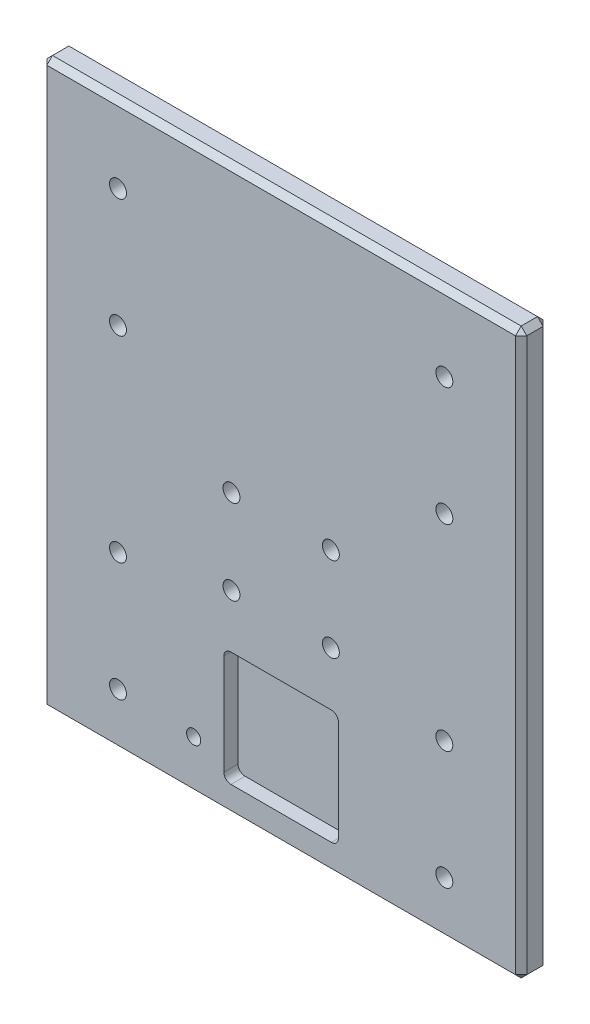
from build123d import *

# Parameters (mm, degrees)
SKETCH1_W           = 107.95
SKETCH1_H           = 127
BOSS_EXTRUDE1_DEPTH = 6.223
CHAMFER1_SIZE       = 1.27
SKETCH2_R           = 1.905
CUT_EXTRUDE1_DEPTH  = 7.223
SKETCH3_R           = 1.905
CUT_EXTRUDE2_DEPTH  = 7.223
SKETCH4_W           = 25.781
SKETCH4_H           = 25.781
CUT_EXTRUDE3_DEPTH  = 3.175
FILLET1_R           = 1.5875
SKETCH5_R           = 1.5875
CUT_EXTRUDE4_DEPTH  = 7.223


with BuildPart() as part:
    # Sketch1 → Boss-Extrude1 (new body)
    with BuildSketch(Plane.XY):
        Rectangle(SKETCH1_W, SKETCH1_H)
    extrude(amount=BOSS_EXTRUDE1_DEPTH)

    # Chamfer1
    chamfer1_edges = [part.edges().sort_by_distance(p)[0] for p in [
        (-53.975, 0, 6.223),
        (0, -63.5, 6.223),
        (53.975, 0, 6.223),
        (0, -63.5, 0),
        (-53.975, 0, 0),
        (0, 63.5, 0),
        (53.975, 0, 0),
        (0, 63.5, 6.223),
        (53.975, -63.5, 3.1115),
        (-53.975, -63.5, 3.1115),
        (-53.975, 63.5, 3.1115),
        (53.975, 63.5, 3.1115),
    ]]
    chamfer(chamfer1_edges, length=CHAMFER1_SIZE)

    # Sketch2 → Cut-Extrude1 (cut, through all)
    with BuildSketch(Plane.XY.offset(6.223)):
        with Locations((-36.703, 46.228)):
            Circle(SKETCH2_R)
        with Locations((-36.703, -51.308)):
            Circle(SKETCH2_R)
        with Locations((36.703, -51.308)):
            Circle(SKETCH2_R)
        with Locations((36.703, 46.228)):
            Circle(SKETCH2_R)
        with Locations((-36.703, 19.558)):
            Circle(SKETCH2_R)
        with Locations((-36.703, -24.638)):
            Circle(SKETCH2_R)
        with Locations((36.703, 19.558)):
            Circle(SKETCH2_R)
        with Locations((36.703, -24.638)):
            Circle(SKETCH2_R)
    extrude(amount=-CUT_EXTRUDE1_DEPTH, mode=Mode.SUBTRACT)

    # Sketch3 → Cut-Extrude2 (cut, through all)
    with BuildSketch(Plane.XY.offset(6.223)):
        with Locations((-11.176, -0.254)):
            Circle(SKETCH3_R)
        with Locations((11.176, -0.254)):
            Circle(SKETCH3_R)
        with Locations((11.176, -19.304)):
            Circle(SKETCH3_R)
        with Locations((-11.176, -19.304)):
            Circle(SKETCH3_R)
    extrude(amount=-CUT_EXTRUDE2_DEPTH, mode=Mode.SUBTRACT)

    # Sketch4 → Cut-Extrude3 (cut)
    with BuildSketch(Plane.XY.offset(6.223)):
        with Locations((0, -44.2595)):
            Rectangle(SKETCH4_W, SKETCH4_H)
    extrude(amount=-CUT_EXTRUDE3_DEPTH, mode=Mode.SUBTRACT)

    # Fillet1
    fillet1_edges = [part.edges().sort_by_distance(p)[0] for p in [
        (12.8905, -31.369, 4.6355),
        (12.8905, -57.15, 4.6355),
        (-12.8905, -57.15, 4.6355),
        (-12.8905, -31.369, 4.6355),
    ]]
    fillet(fillet1_edges, radius=FILLET1_R)

    # Sketch5 → Cut-Extrude4 (cut, through all)
    with BuildSketch(Plane.XY.offset(6.223)):
        with Locations((-19.685, -52.07)):
            Circle(SKETCH5_R)
    extrude(amount=-CUT_EXTRUDE4_DEPTH, mode=Mode.SUBTRACT)


solid = part.part
